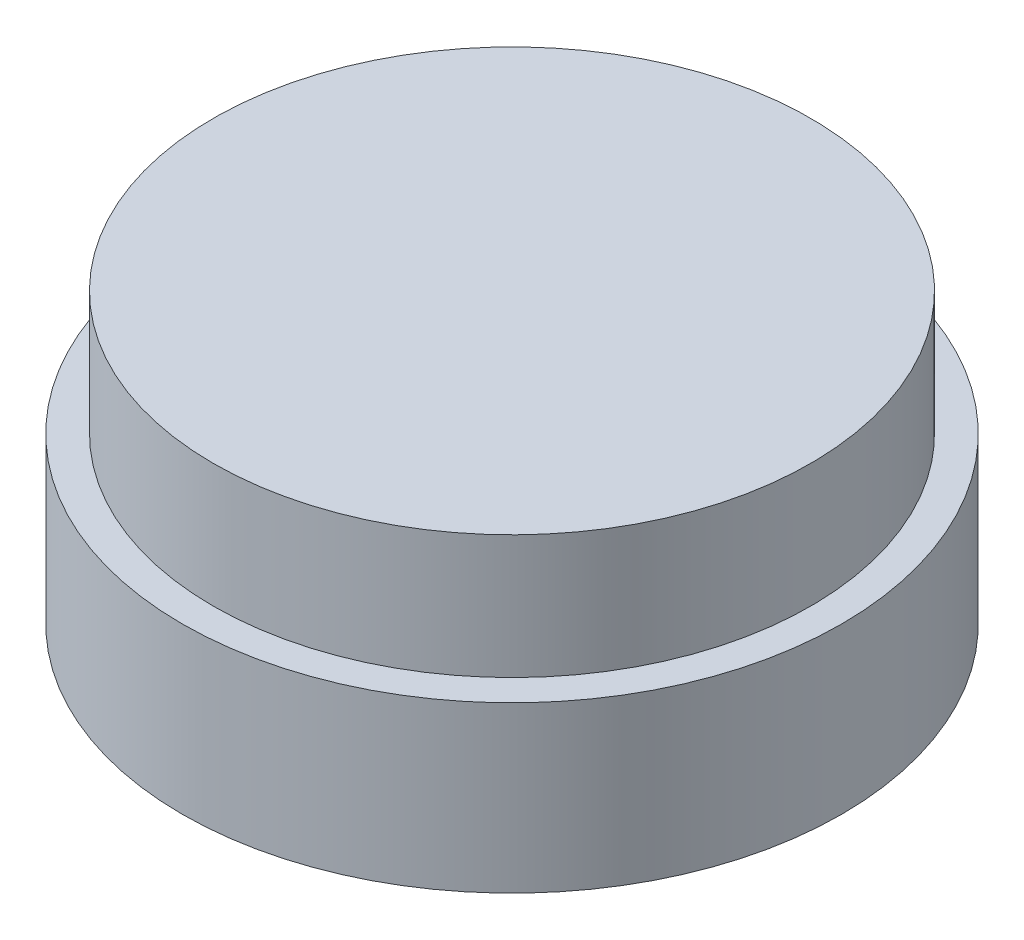
from build123d import *

# Parameters (mm, degrees)
SZKIC1_R                    = 8
DODANIE_WYCI_GNI_CIE2_DEPTH = 4
SZKIC2_R                    = 7.25
DODANIE_WYCI_GNI_CIE4_DEPTH = 3


with BuildPart() as part:
    # Szkic1 → Dodanie-wyciągnięcie2 (new body)
    with BuildSketch(Plane(origin=(0, 0, 0), x_dir=(1, 0, 0), z_dir=(0, 1, 0))):
        Circle(SZKIC1_R)
    extrude(amount=DODANIE_WYCI_GNI_CIE2_DEPTH)

    # Szkic2 → Dodanie-wyciągnięcie4 (add)
    with BuildSketch(Plane(origin=(0, 4, 0), x_dir=(1, 0, 0), z_dir=(0, 1, 0))):
        Circle(SZKIC2_R)
    extrude(amount=DODANIE_WYCI_GNI_CIE4_DEPTH)


solid = part.part
